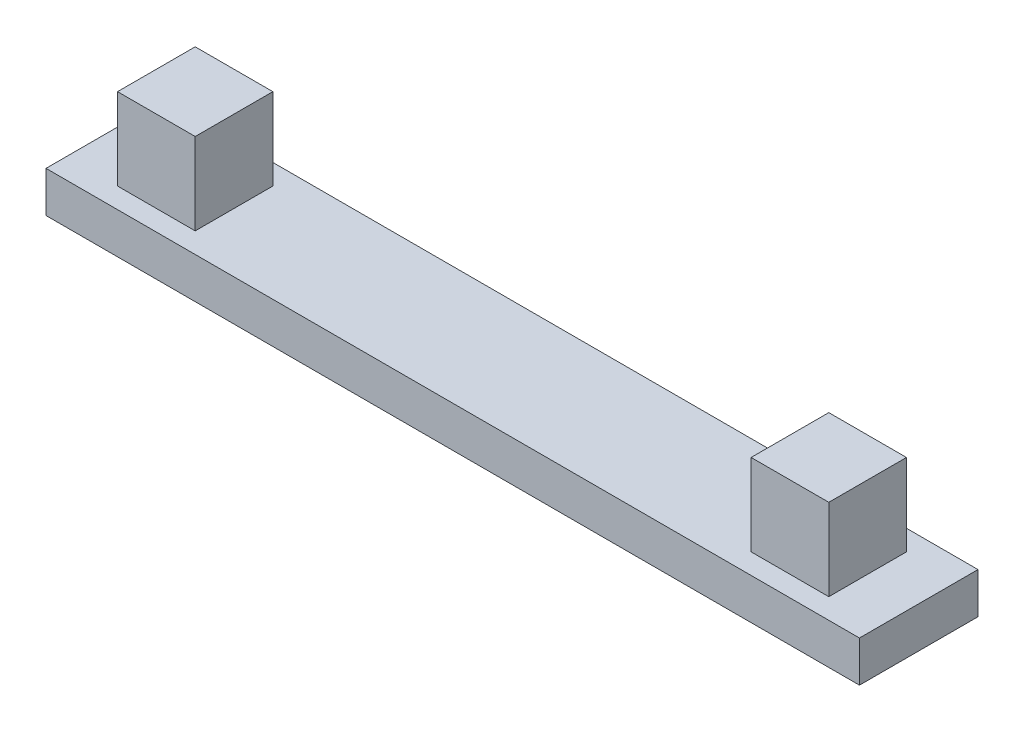
from build123d import *

# Parameters (mm, degrees)
SKETCH1_W           = 19.9
SKETCH1_H           = 2.9
SKETCH1_W_2         = 1.9
SKETCH1_H_2         = 1.9
BOSS_EXTRUDE1_DEPTH = 1
SKETCH1_3_W         = 1.9
SKETCH1_3_H         = 1.9
BOSS_EXTRUDE2_DEPTH = 3


with BuildPart() as part:
    # Sketch1 → Boss-Extrude1 (new body)
    with BuildSketch(Plane(origin=(0, 0, 0), x_dir=(1, 0, 0), z_dir=(0, 1, 0))):
        with Locations((9.95, 1.45)):
            Rectangle(SKETCH1_W, SKETCH1_H)
        with Locations((2.2, 1.45)):
            Rectangle(SKETCH1_W_2, SKETCH1_H_2, mode=Mode.SUBTRACT)
        with Locations((17.7, 1.45)):
            Rectangle(SKETCH1_W_2, SKETCH1_H_2, mode=Mode.SUBTRACT)
    extrude(amount=BOSS_EXTRUDE1_DEPTH)

    # Sketch1_3 → Boss-Extrude2 (add)
    with BuildSketch(Plane(origin=(0, 0, 0), x_dir=(1, 0, 0), z_dir=(0, 1, 0))):
        with Locations((2.2, 1.45)):
            Rectangle(SKETCH1_3_W, SKETCH1_3_H)
        with Locations((17.7, 1.45)):
            Rectangle(SKETCH1_3_W, SKETCH1_3_H)
    extrude(amount=BOSS_EXTRUDE2_DEPTH)


solid = part.part
